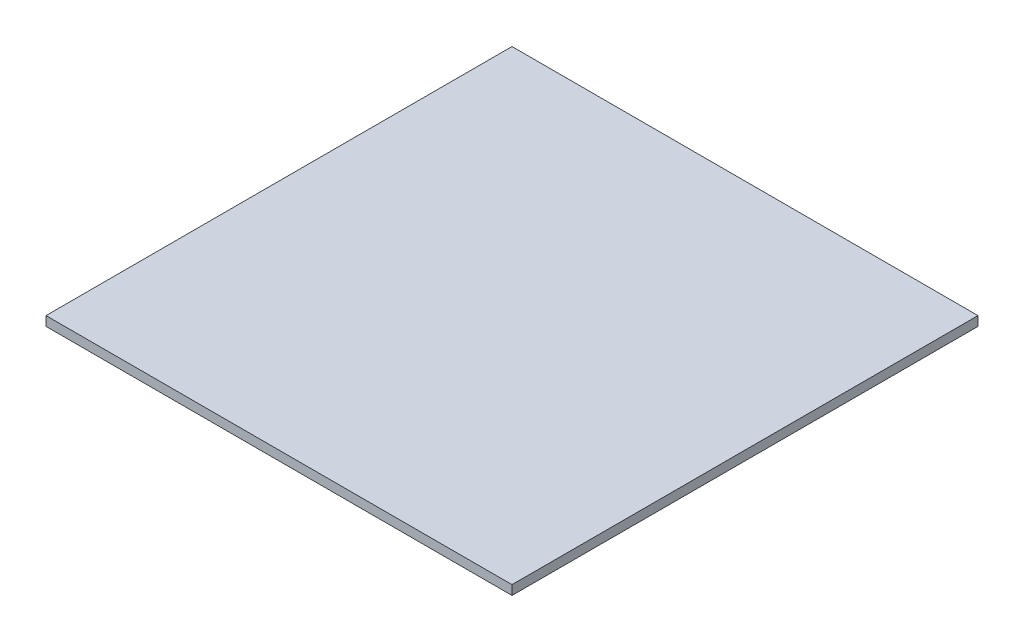
from build123d import *

# Parameters (mm, degrees)
SKETCH2_W           = 150
SKETCH2_H           = 150
BOSS_EXTRUDE1_DEPTH = 3.021249995


with BuildPart() as part:
    # Sketch2 → Boss-Extrude1 (new body)
    with BuildSketch(Plane(origin=(0, 0, 0), x_dir=(1, 0, 0), z_dir=(0, 1, 0))):
        with Locations((75, 75)):
            Rectangle(SKETCH2_W, SKETCH2_H)
    extrude(amount=BOSS_EXTRUDE1_DEPTH)


solid = part.part
